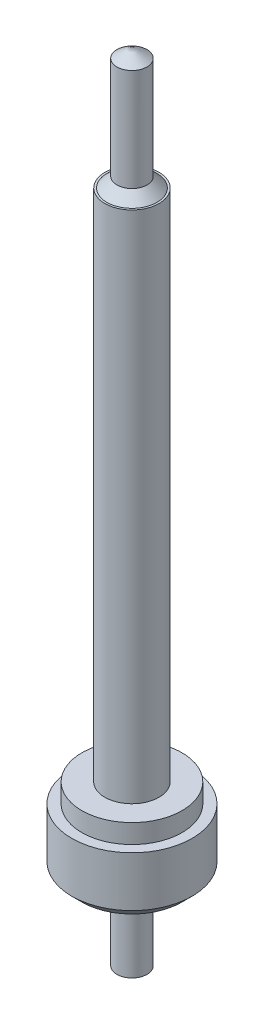
from build123d import *

# Parameters (mm, degrees)
SKETCH2_R           = 0.3
BOSS_EXTRUDE1_DEPTH = 0.3
SKETCH3_R           = 0.075
BOSS_EXTRUDE2_DEPTH = 0.45
SKETCH4_R           = 0.25
BOSS_EXTRUDE3_DEPTH = 0.095
SKETCH5_R           = 0.135
BOSS_EXTRUDE4_DEPTH = 2.565
SKETCH6_R           = 0.075
BOSS_EXTRUDE5_DEPTH = 0.61
CHAMFER1_SIZE       = 0.05
CHAMFER1_SIZE2      = 0.075
CHAMFER2_SIZE       = 0.05
CHAMFER3_SIZE       = 0.05
CHAMFER4_SIZE       = 0.05
CHAMFER4_SIZE2      = 0.075


with BuildPart() as part:
    # Sketch2 → Boss-Extrude1 (new body)
    with BuildSketch(Plane(origin=(0, 0, 0), x_dir=(1, 0, 0), z_dir=(0, 1, 0))):
        Circle(SKETCH2_R)
    extrude(amount=-BOSS_EXTRUDE1_DEPTH)

    # Sketch3 → Boss-Extrude2 (add)
    with BuildSketch(Plane.XZ.offset(0.3)):
        Circle(SKETCH3_R)
    extrude(amount=BOSS_EXTRUDE2_DEPTH)

    # Sketch4 → Boss-Extrude3 (add)
    with BuildSketch(Plane(origin=(0, 0, 0), x_dir=(1, 0, 0), z_dir=(0, 1, 0))):
        Circle(SKETCH4_R)
    extrude(amount=BOSS_EXTRUDE3_DEPTH)

    # Sketch5 → Boss-Extrude4 (add)
    with BuildSketch(Plane(origin=(0, 0.095, 0), x_dir=(1, 0, 0), z_dir=(0, 1, 0))):
        Circle(SKETCH5_R)
    extrude(amount=BOSS_EXTRUDE4_DEPTH)

    # Sketch6 → Boss-Extrude5 (add)
    with BuildSketch(Plane(origin=(0, 2.66, 0), x_dir=(1, 0, 0), z_dir=(0, 1, 0))):
        Circle(SKETCH6_R)
    extrude(amount=BOSS_EXTRUDE5_DEPTH)

    # Chamfer1
    chamfer1_edges = [part.edges().sort_by_distance(p)[0] for p in [
        (-0.075, -0.75, 0),
    ]]
    chamfer1_side = [part.faces().sort_by_distance(p)[0] for p in [
        (-0.075, -0.525, 0),
    ]]
    chamfer(chamfer1_edges, length=CHAMFER1_SIZE, length2=CHAMFER1_SIZE2, reference=chamfer1_side[0])

    # Chamfer2
    chamfer2_edges = [part.edges().sort_by_distance(p)[0] for p in [
        (-0.3, -0.3, 0),
    ]]
    chamfer(chamfer2_edges, length=CHAMFER2_SIZE)

    # Chamfer3
    chamfer3_edges = [part.edges().sort_by_distance(p)[0] for p in [
        (-0.075, 2.66, 0),
    ]]
    chamfer(chamfer3_edges, length=CHAMFER3_SIZE)

    # Chamfer4
    chamfer4_edges = [part.edges().sort_by_distance(p)[0] for p in [
        (-0.075, 3.27, 0),
    ]]
    chamfer4_side = [part.faces().sort_by_distance(p)[0] for p in [
        (-0.075, 2.99, 0),
    ]]
    chamfer(chamfer4_edges, length=CHAMFER4_SIZE, length2=CHAMFER4_SIZE2, reference=chamfer4_side[0])


solid = part.part
